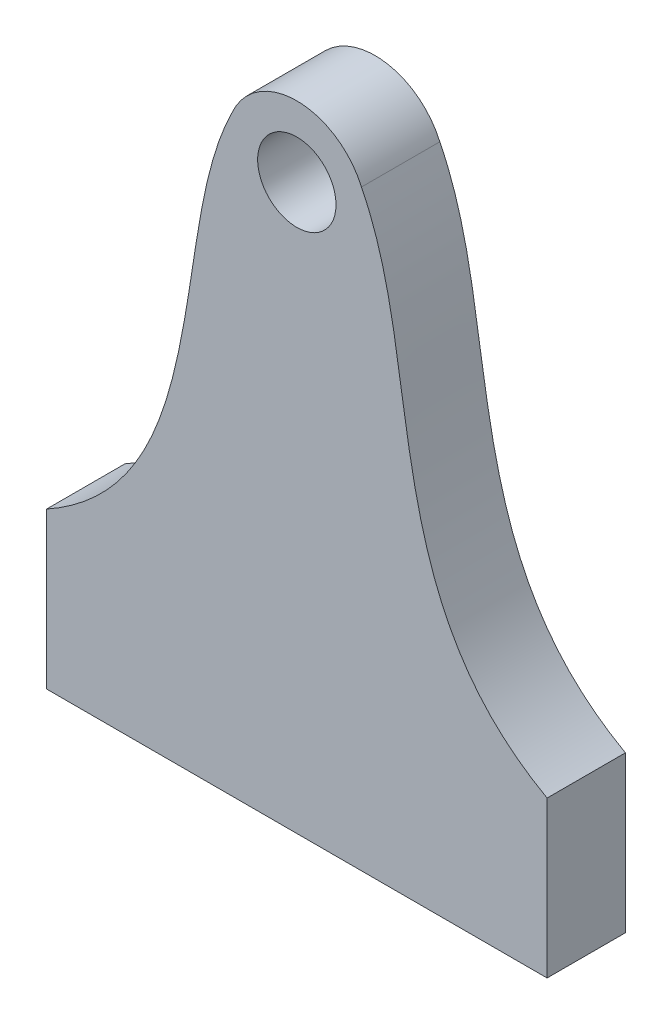
from build123d import *

# Parameters (mm, degrees)
SKETCH1_R           = 3.175
BOSS_EXTRUDE1_DEPTH = 6.35


with BuildPart() as part:
    # Sketch1 → Boss-Extrude1 (new body)
    with BuildSketch(Plane.XY):
        with BuildLine():
            Line((20.284910643, 0), (20.284910643, 12.632459137))
            add(Edge.make_bspline(
                [(20.284910643, 12.632459137), (11.321554309, 17.627045812), (9.14548831, 30.766646824), (7.127170197, 44.232555484), (5.239939742, 48.001283958)],
                knots=[0, 0, 0, 0, 0.567527293, 0.844926431, 0.844926431, 0.844926431, 0.844926431], degree=3))
            ThreePointArc((5.239939742, 48.001283958), (0, 51.435), (-5.239939742, 48.001283958))
            add(Edge.make_bspline(
                [(-20.284910643, 12.632459137), (-11.321554309, 17.627045812), (-9.14548831, 30.766646824), (-7.127170197, 44.232555484), (-5.239939742, 48.001283958)],
                knots=[0, 0, 0, 0, 0.567527293, 0.844926431, 0.844926431, 0.844926431, 0.844926431], degree=3))
            Line((-20.284910643, 12.632459137), (-20.284910643, 0))
            Line((-20.284910643, 0), (20.284910643, 0))
        make_face()
        with Locations((0, 45.72)):
            Circle(SKETCH1_R, mode=Mode.SUBTRACT)
    extrude(amount=BOSS_EXTRUDE1_DEPTH)


solid = part.part
